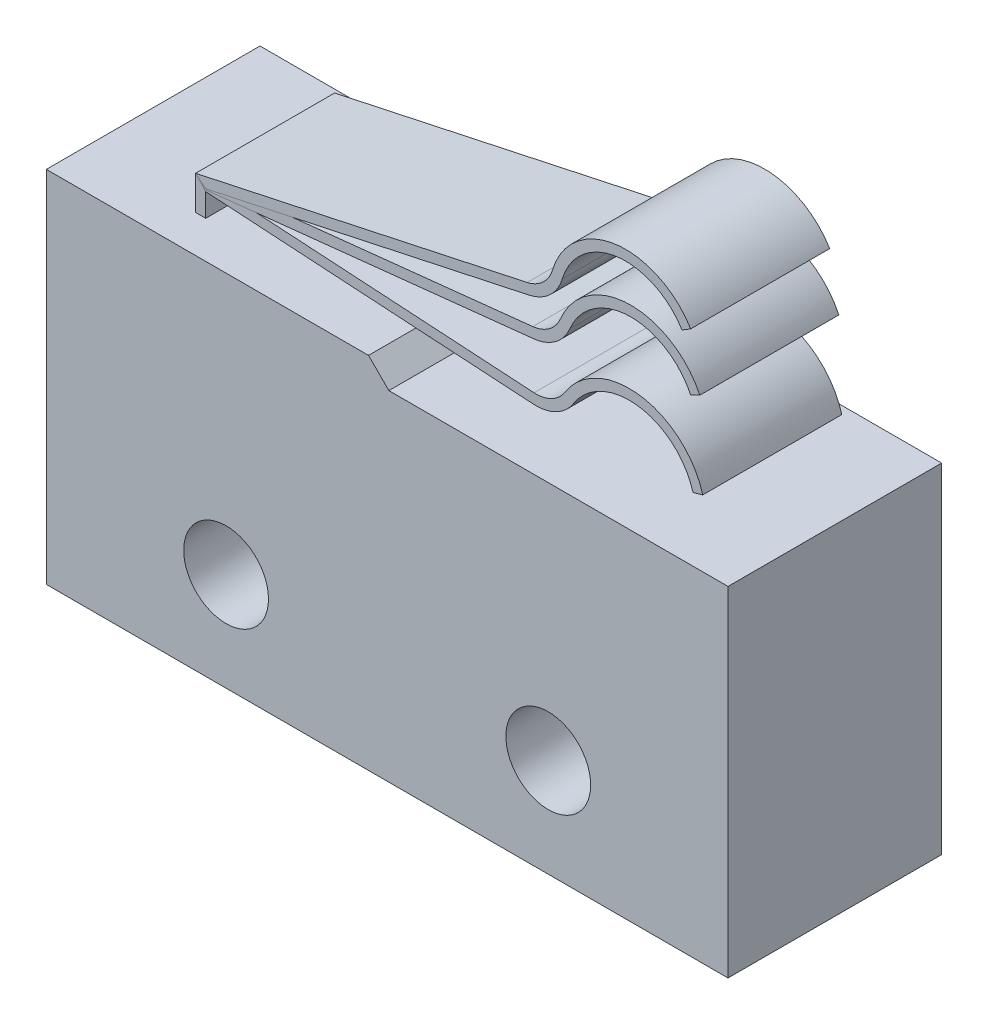
from build123d import *

# Parameters (mm, degrees)
SKETCH1_R           = 1.25
BOSS_EXTRUDE1_DEPTH = 3.15
BOSS_EXTRUDE2_DEPTH = 2.05
BOSS_EXTRUDE3_DEPTH = 2.05
BOSS_EXTRUDE4_DEPTH = 2.05


with BuildPart() as part:
    # Sketch1 → Boss-Extrude1 (new body, symmetric)
    with BuildSketch(Plane.XY):
        Polygon((4.2, 7.7), (4.8, 7.1), (14.8, 7.1), (14.8, -2.9), (-5.3, -2.9), (-5.3, 7.7), align=None)
        Circle(SKETCH1_R, mode=Mode.SUBTRACT)
        with Locations((9.5, 0)):
            Circle(SKETCH1_R, mode=Mode.SUBTRACT)
    extrude(amount=BOSS_EXTRUDE1_DEPTH, both=True)


with BuildPart() as body_2:
    # Sketch2 → Boss-Extrude2 (new body, symmetric)
    with BuildSketch(Plane.XY):
        with BuildLine():
            Line((-2, 7.7), (-2, 8.7))
            Line((-2, 8.7), (7.777013859, 10.8))
            ThreePointArc((7.777013859, 10.8), (8.246050439, 11.04359695), (8.52540848, 11.492254806))
            ThreePointArc((8.52540848, 11.492254806), (10.389553224, 13.080940147), (12.6, 12.02600802))
            Line((12.6, 12.02600802), (12.344239517, 11.869206951))
            ThreePointArc((12.344239517, 11.869206951), (10.428518978, 12.783481461), (8.812926867, 11.406620832))
            ThreePointArc((8.812926867, 11.406620832), (8.449761413, 10.823365619), (7.840013859, 10.506689584))
            Line((7.840013859, 10.506689584), (-1.7, 8.457594698))
            Line((-1.7, 8.457594698), (-1.7, 7.7))
            Line((-1.7, 7.7), (-2, 7.7))
        make_face()
    extrude(amount=BOSS_EXTRUDE2_DEPTH, both=True)


with BuildPart() as body_3:
    # Sketch3 → Boss-Extrude3 (new body, symmetric)
    with BuildSketch(Plane.XY):
        with BuildLine():
            Line((-2, 7.7), (-2, 8.7))
            Line((-2, 8.7), (7.944007232, 9.756749817))
            ThreePointArc((7.944007232, 9.756749817), (8.436126819, 9.949501207), (8.761261588, 10.366181143))
            ThreePointArc((8.761261588, 10.366181143), (10.782617164, 11.749321908), (12.869425577, 10.467063202))
            Line((12.869425577, 10.467063202), (12.59854918, 10.338121442))
            ThreePointArc((12.59854918, 10.338121442), (10.789981889, 11.44941232), (9.03814039, 10.250690324))
            ThreePointArc((9.03814039, 10.250690324), (8.61546519, 9.709006407), (7.975709726, 9.4584296))
            Line((7.975709726, 9.4584296), (-1.7, 8.430191763))
            Line((-1.7, 8.430191763), (-1.7, 7.7))
            Line((-1.7, 7.7), (-2, 7.7))
        make_face()
    extrude(amount=BOSS_EXTRUDE3_DEPTH, both=True)


with BuildPart() as body_4:
    # Sketch4 → Boss-Extrude4 (new body, symmetric)
    with BuildSketch(Plane.XY):
        with BuildLine():
            Line((-2, 8.7), (-2, 7.7))
            Line((-2, 7.7), (-1.7, 7.7))
            Line((-1.7, 7.7), (-1.7, 8.38095514))
            Line((-1.7, 8.38095514), (7.962646813, 7.785850956))
            ThreePointArc((7.962646813, 7.785850956), (8.635207878, 7.926340826), (9.142221759, 8.390035461))
            ThreePointArc((9.142221759, 8.390035461), (11.069289918, 9.280142968), (12.667436983, 7.88307138))
            Line((12.667436983, 7.88307138), (12.956009676, 7.965082361))
            ThreePointArc((12.956009676, 7.965082361), (11.111993832, 9.57708804), (8.888453648, 8.550040917))
            ThreePointArc((8.888453648, 8.550040917), (8.498442971, 8.193352736), (7.981088305, 8.085283605))
            Line((7.981088305, 8.085283605), (-2, 8.7))
        make_face()
    extrude(amount=BOSS_EXTRUDE4_DEPTH, both=True)


solid = Compound([part.part, body_2.part, body_3.part, body_4.part])
